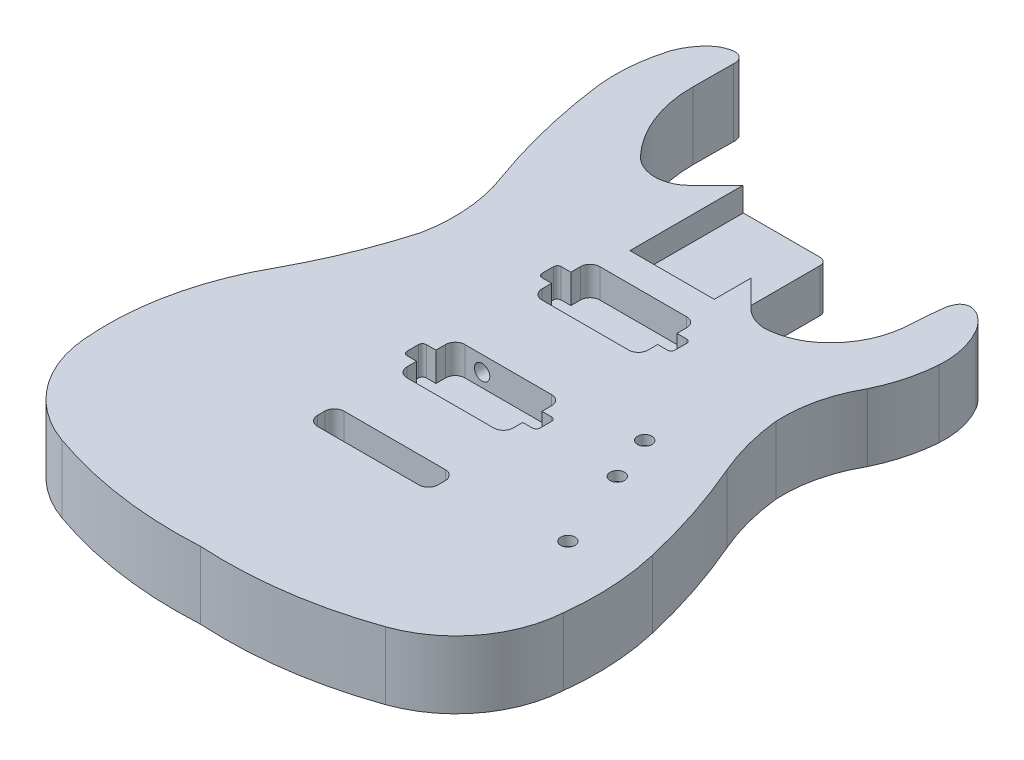
from build123d import *

# Parameters (mm, degrees)
BOSS_EXTRUDE1_DEPTH     = 22.225
CUT_EXTRUDE1_DEPTH      = 15.875
CUT_EXTRUDE2_DEPTH      = 19.05
CUT_EXTRUDE3_DEPTH      = 19.05
CUT_EXTRUDE4_DEPTH      = 15.875
CUT_EXTRUDE5_DEPTH      = 1
CUT_EXTRUDE5_DEPTH_BACK = 45.45
CUT_EXTRUDE6_DEPTH      = 38.1
SKETCH9_R               = 4.75
CUT_EXTRUDE7_DEPTH      = 39.1
CUT_EXTRUDE7_DEPTH_BACK = 7.35
SKETCH10_R              = 5.08
CUT_EXTRUDE8_DEPTH      = 38.1
CUT_EXTRUDE8_DEPTH_BACK = 38.1
SKETCH14_R              = 5.08
CUT_EXTRUDE9_DEPTH      = 88.9


with BuildPart() as part:
    # Sketch1 → Boss-Extrude1 (new body, symmetric)
    with BuildSketch(Plane(origin=(0, 0, 0), x_dir=(1, 0, 0), z_dir=(0, 1, 0))):
        with BuildLine():
            Line((-27.139164257, 167.796683689), (23.215337255, 167.796683689))
            ThreePointArc((23.215337255, 167.796683689), (26.553400644, 166.414012561), (27.936071772, 163.075949172))
            Line((27.936071772, 163.075949172), (27.936071772, 117.442182176))
            Line((27.936071772, 117.442182176), (45.739076513, 99.639177435))
            ThreePointArc((45.739076513, 99.639177435), (52.653298853, 95.043473949), (60.717629895, 93.070271999))
            ThreePointArc((60.717629895, 93.070271999), (72.137749756, 94.950404711), (82.719311408, 99.639177435))
            ThreePointArc((82.719311408, 99.639177435), (99.088819495, 116.502407503), (106.691226482, 138.740499404))
            ThreePointArc((106.691226482, 138.740499404), (107.293250165, 146.399208048), (107.783318293, 154.065894676))
            ThreePointArc((107.783318293, 154.065894676), (108.340552038, 159.17256706), (108.853679748, 164.283859678))
            ThreePointArc((108.853679748, 164.283859678), (109.705429788, 167.387313473), (111.11535679, 170.2802375))
            ThreePointArc((111.11535679, 170.2802375), (113.620556723, 172.466184723), (116.845200472, 173.276162908))
            ThreePointArc((116.845200472, 173.276162908), (120.221594265, 172.465675408), (123.355683212, 170.970880603))
            ThreePointArc((123.355683212, 170.970880603), (128.265134652, 166.745027029), (132.181680011, 161.585451046))
            ThreePointArc((132.181680011, 161.585451046), (138.33428397, 146.199471549), (139.619453347, 129.678840803))
            ThreePointArc((139.619453347, 129.678840803), (136.39277719, 110.641651914), (129.659662699, 92.544934835))
            ThreePointArc((129.659662699, 92.544934835), (120.370646129, 69.036558024), (118.071361376, 43.864293549))
            ThreePointArc((118.071361376, 43.864293549), (122.222572829, 21.498106395), (129.659662699, 0))
            ThreePointArc((129.659662699, 0), (143.398814545, -36.155916163), (153.856513267, -73.393680656))
            ThreePointArc((153.856513267, -73.393680656), (158.275027292, -104.230564471), (157.301620264, -135.367185167))
            ThreePointArc((157.301620264, -135.367185167), (141.975051177, -176.275361149), (106.691226482, -202.032579498))
            ThreePointArc((106.691226482, -202.032579498), (54.098789107, -214.895017574), (0, -217.069367939))
            ThreePointArc((0, -217.069367939), (-54.004742533, -214.862710734), (-106.509687866, -202.032579498))
            ThreePointArc((-106.509687866, -202.032579498), (-141.094553776, -177.085698472), (-156.684587611, -137.394255213))
            ThreePointArc((-156.684587611, -137.394255213), (-153.316704731, -83.564621207), (-134.097306667, -33.170307338))
            ThreePointArc((-134.097306667, -33.170307338), (-118.452837363, -0.106574858), (-106.509687848, 34.466839857))
            ThreePointArc((-106.509687848, 34.466839857), (-104.952609842, 63.858154337), (-111.536110603, 92.544934857))
            ThreePointArc((-111.536110603, 92.544934857), (-124.146260861, 134.317832636), (-132.040568435, 177.232524599))
            ThreePointArc((-132.040568435, 177.232524599), (-132.180605283, 199.253892218), (-127.895077973, 220.854690763))
            ThreePointArc((-127.895077973, 220.854690763), (-123.677084376, 229.09027242), (-117.65146136, 236.112248103))
            ThreePointArc((-117.65146136, 236.112248103), (-112.585214143, 239.486704693), (-106.727388664, 241.141908245))
            ThreePointArc((-106.727388664, 241.141908245), (-101.521494245, 239.144724173), (-99.844107934, 233.82716307))
            Line((-99.844107934, 233.82716307), (-100.045578427, 207.171189317))
            ThreePointArc((-100.045578427, 207.171189317), (-94.278032432, 176.375383516), (-77.376792667, 149.993678943))
            ThreePointArc((-77.376792667, 149.993678943), (-61.159480832, 143.276248437), (-44.942168999, 149.993678947))
            Line((-44.942168999, 149.993678947), (-27.139164257, 167.796683689))
        make_face()
    extrude(amount=BOSS_EXTRUDE1_DEPTH, both=True)

    # Sketch2 → Cut-Extrude1 (cut)
    with BuildSketch(Plane(origin=(0, 22.225, 0), x_dir=(1, 0, 0), z_dir=(0, 1, 0))):
        with BuildLine():
            Line((-27.379271025, 93.081221646), (-27.379271025, 167.796683689))
            Line((-27.379271025, 167.796683689), (23.215337255, 167.796683689))
            ThreePointArc((23.215337255, 167.796683689), (26.728167178, 166.341621892), (28.183228975, 162.828791969))
            Line((28.183228975, 162.828791969), (28.183228975, 93.081221646))
            Line((28.183228975, 93.081221646), (-27.379271025, 93.081221646))
        make_face()
    extrude(amount=-CUT_EXTRUDE1_DEPTH, mode=Mode.SUBTRACT)

    # Sketch3 → Cut-Extrude2 (cut)
    with BuildSketch(Plane(origin=(0, 22.225, 0), x_dir=(1, 0, 0), z_dir=(0, 1, 0))):
        with BuildLine():
            Line((-40.873021025, -27.568778354), (-34.523021025, -27.568778354))
            Line((-34.523021025, -27.568778354), (-34.523021025, -21.218778354))
            ThreePointArc((-34.523021025, -21.218778354), (-32.663149086, -16.728650294), (-28.173021025, -14.868778354))
            Line((-28.173021025, -14.868778354), (28.976978975, -14.868778354))
            ThreePointArc((28.976978975, -14.868778354), (33.467107035, -16.728650294), (35.326978975, -21.218778354))
            Line((35.326978975, -21.218778354), (35.326978975, -27.568778354))
            Line((35.326978975, -27.568778354), (41.676978975, -27.568778354))
            ThreePointArc((41.676978975, -27.568778354), (43.473030199, -28.31272713), (44.216978975, -30.108778354))
            Line((44.216978975, -30.108778354), (44.216978975, -37.728778354))
            ThreePointArc((44.216978975, -37.728778354), (43.473030199, -39.524829578), (41.676978975, -40.268778354))
            Line((41.676978975, -40.268778354), (35.326978975, -40.268778354))
            Line((35.326978975, -40.268778354), (35.326978975, -46.618778354))
            ThreePointArc((35.326978975, -46.618778354), (33.467107035, -51.108906415), (28.976978975, -52.968778354))
            Line((28.976978975, -52.968778354), (-28.173021025, -52.968778354))
            ThreePointArc((-28.173021025, -52.968778354), (-32.663149086, -51.108906415), (-34.523021025, -46.618778354))
            Line((-34.523021025, -46.618778354), (-34.523021025, -40.268778354))
            Line((-34.523021025, -40.268778354), (-40.873021025, -40.268778354))
            ThreePointArc((-40.873021025, -40.268778354), (-42.66907225, -39.524829578), (-43.413021025, -37.728778354))
            Line((-43.413021025, -37.728778354), (-43.413021025, -30.108778354))
            ThreePointArc((-43.413021025, -30.108778354), (-42.66907225, -28.31272713), (-40.873021025, -27.568778354))
        make_face()
    extrude(amount=-CUT_EXTRUDE2_DEPTH, mode=Mode.SUBTRACT)

    # Sketch4 → Cut-Extrude3 (cut)
    with BuildSketch(Plane(origin=(0, 22.225, 0), x_dir=(1, 0, 0), z_dir=(0, 1, 0))):
        with BuildLine():
            Line((-40.873021025, 61.331221646), (-34.523021025, 61.331221646))
            Line((-34.523021025, 61.331221646), (-34.523021025, 67.681221646))
            ThreePointArc((-34.523021025, 67.681221646), (-32.663149086, 72.171349706), (-28.173021025, 74.031221646))
            Line((-28.173021025, 74.031221646), (28.976978975, 74.031221646))
            ThreePointArc((28.976978975, 74.031221646), (33.467107035, 72.171349706), (35.326978975, 67.681221646))
            Line((35.326978975, 67.681221646), (35.326978975, 61.331221646))
            Line((35.326978975, 61.331221646), (41.676978975, 61.331221646))
            ThreePointArc((41.676978975, 61.331221646), (43.473030199, 60.58727287), (44.216978975, 58.791221646))
            Line((44.216978975, 58.791221646), (44.216978975, 51.171221646))
            ThreePointArc((44.216978975, 51.171221646), (43.473030199, 49.375170422), (41.676978975, 48.631221646))
            Line((41.676978975, 48.631221646), (35.326978975, 48.631221646))
            Line((35.326978975, 48.631221646), (35.326978975, 42.281221646))
            ThreePointArc((35.326978975, 42.281221646), (33.467107035, 37.791093585), (28.976978975, 35.931221646))
            Line((28.976978975, 35.931221646), (-28.173021025, 35.931221646))
            ThreePointArc((-28.173021025, 35.931221646), (-32.663149086, 37.791093585), (-34.523021025, 42.281221646))
            Line((-34.523021025, 42.281221646), (-34.523021025, 48.631221646))
            Line((-34.523021025, 48.631221646), (-40.873021025, 48.631221646))
            ThreePointArc((-40.873021025, 48.631221646), (-42.66907225, 49.375170422), (-43.413021025, 51.171221646))
            Line((-43.413021025, 51.171221646), (-43.413021025, 58.791221646))
            ThreePointArc((-43.413021025, 58.791221646), (-42.66907225, 60.58727287), (-40.873021025, 61.331221646))
        make_face()
    extrude(amount=-CUT_EXTRUDE3_DEPTH, mode=Mode.SUBTRACT)

    # Sketch5 → Cut-Extrude4 (cut)
    with BuildSketch(Plane.XZ.offset(22.225)):
        with BuildLine():
            Line((-36.295157608, 111.718978354), (-36.295157608, -0.295021646))
            ThreePointArc((-36.295157608, -0.295021646), (-34.435285668, -4.785149706), (-29.945157608, -6.645021646))
            Line((-29.945157608, -6.645021646), (36.729842392, -6.645021646))
            ThreePointArc((36.729842392, -6.645021646), (41.219970453, -4.785149706), (43.079842392, -0.295021646))
            Line((43.079842392, -0.295021646), (43.079842392, 111.718978354))
            ThreePointArc((43.079842392, 111.718978354), (41.219970453, 116.209106415), (36.729842392, 118.068978354))
            Line((36.729842392, 118.068978354), (-29.945157608, 118.068978354))
            ThreePointArc((-29.945157608, 118.068978354), (-34.435285668, 116.209106415), (-36.295157608, 111.718978354))
        make_face()
    extrude(amount=-CUT_EXTRUDE4_DEPTH, mode=Mode.SUBTRACT)

    # Sketch6 → Cut-Extrude5 (cut, two sides)
    with BuildSketch(Plane.XZ.offset(22.225)) as cut_extrude5_sk:
        with BuildLine():
            Line((-29.945157608, 110.118778354), (36.729842392, 110.118778354))
            ThreePointArc((36.729842392, 110.118778354), (41.219970453, 108.258906415), (43.079842392, 103.768778354))
            Line((43.079842392, 103.768778354), (43.079842392, 99.018978354))
            ThreePointArc((43.079842392, 99.018978354), (41.219970453, 94.528850294), (36.729842392, 92.668978354))
            Line((36.729842392, 92.668978354), (-29.945157608, 92.668978354))
            ThreePointArc((-29.945157608, 92.668978354), (-34.435285668, 94.528850294), (-36.295157608, 99.018978354))
            Line((-36.295157608, 99.018978354), (-36.295157608, 103.768778354))
            ThreePointArc((-36.295157608, 103.768778354), (-34.435285668, 108.258906415), (-29.945157608, 110.118778354))
        make_face()
    extrude(amount=CUT_EXTRUDE5_DEPTH, mode=Mode.SUBTRACT)
    extrude(cut_extrude5_sk.sketch, amount=-CUT_EXTRUDE5_DEPTH_BACK, mode=Mode.SUBTRACT)

    # Sketch7 → Cut-Extrude6 (cut)
    with BuildSketch(Plane.XZ.offset(22.225)):
        with BuildLine():
            Line((63.367094077, -12.151361373), (108.743204002, 103.892460729))
            ThreePointArc((108.743204002, 103.892460729), (125.196118422, 111.095349531), (132.399007223, 94.642435111))
            Line((132.399007223, 94.642435111), (87.022897298, -21.401386992))
            ThreePointArc((87.022897298, -21.401386992), (70.569982878, -28.604275793), (63.367094077, -12.151361373))
        make_face()
    extrude(amount=-CUT_EXTRUDE6_DEPTH, mode=Mode.SUBTRACT)

    # Sketch9 → Cut-Extrude7 (cut, two sides)
    with BuildSketch(Plane.XZ.offset(-15.875)) as cut_extrude7_sk:
        with Locations((85.754227465, 10.292205969)):
            Circle(SKETCH9_R)
        with Locations((97.267975655, 39.880989361)):
            Circle(SKETCH9_R)
        with Locations((117.992722398, 93.140799466)):
            Circle(SKETCH9_R)
    extrude(amount=CUT_EXTRUDE7_DEPTH, mode=Mode.SUBTRACT)
    extrude(cut_extrude7_sk.sketch, amount=-CUT_EXTRUDE7_DEPTH_BACK, mode=Mode.SUBTRACT)

    # Sketch10 → Cut-Extrude8 (cut, two sides)
    with BuildSketch(Plane.XY) as cut_extrude8_sk:
        with Locations((-16.812366699, 12.116016476)):
            Circle(SKETCH10_R)
    extrude(amount=CUT_EXTRUDE8_DEPTH, mode=Mode.SUBTRACT)
    extrude(cut_extrude8_sk.sketch, amount=-CUT_EXTRUDE8_DEPTH_BACK, mode=Mode.SUBTRACT)

    # Sketch14 → Cut-Extrude9 (cut)
    with BuildSketch(Plane(origin=(44.388567954, 0, 22.168329827), x_dir=(0.446795069, 0, -0.894636332), z_dir=(0.894636332, 0, 0.446795069))):
        with Locations((-30.324577812, 12.371154411)):
            Circle(SKETCH14_R)
    extrude(amount=CUT_EXTRUDE9_DEPTH, mode=Mode.SUBTRACT)


solid = part.part
